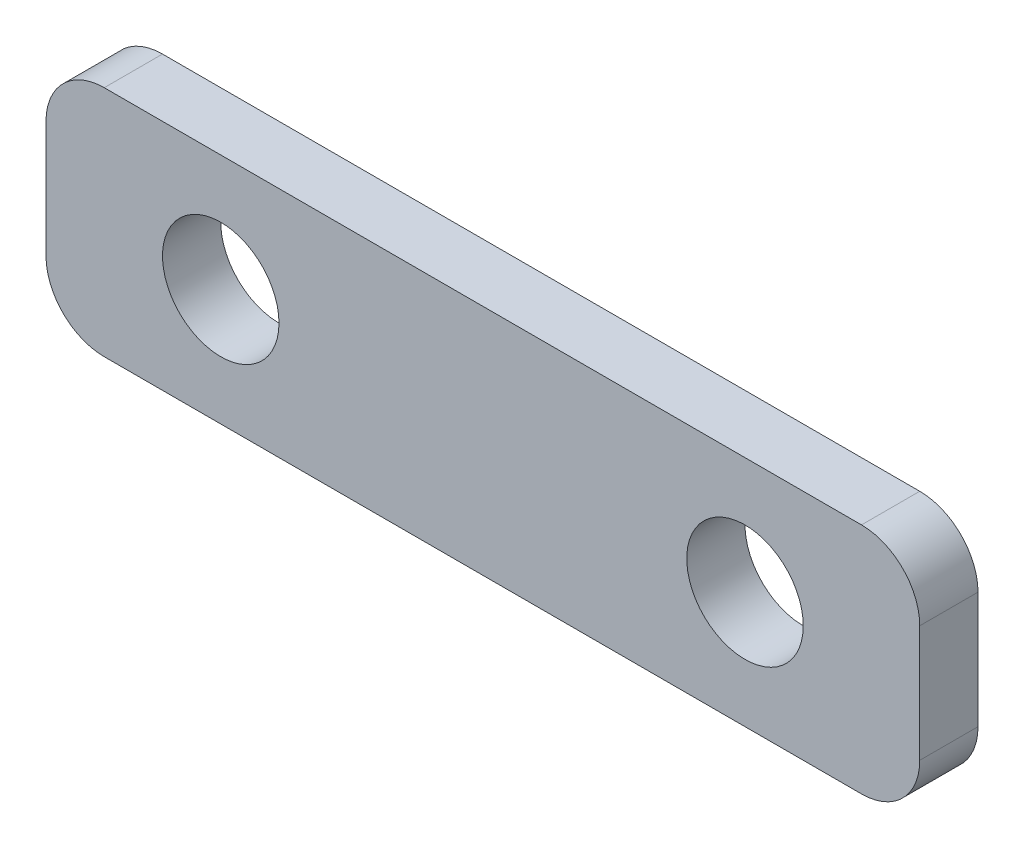
from build123d import *

# Parameters (mm, degrees)
SKETCH1_R           = 10
BOSS_EXTRUDE1_DEPTH = 5


with BuildPart() as part:
    # Sketch1 → Boss-Extrude1 (new body, symmetric)
    with BuildSketch(Plane.XY):
        with BuildLine():
            Line((-190, 151.755891263), (-60, 151.755891263))
            ThreePointArc((-60, 151.755891263), (-52.928932188, 148.826959075), (-50, 141.755891263))
            Line((-50, 141.755891263), (-50, 121.755891263))
            ThreePointArc((-50, 121.755891263), (-52.928932188, 114.684823451), (-60, 111.755891263))
            Line((-60, 111.755891263), (-190, 111.755891263))
            ThreePointArc((-190, 111.755891263), (-197.071067812, 114.684823451), (-200, 121.755891263))
            Line((-200, 121.755891263), (-200, 141.755891263))
            ThreePointArc((-200, 141.755891263), (-197.071067812, 148.826959075), (-190, 151.755891263))
        make_face()
        with Locations((-170, 131.755891263)):
            Circle(SKETCH1_R, mode=Mode.SUBTRACT)
        with Locations((-80, 131.755891263)):
            Circle(SKETCH1_R, mode=Mode.SUBTRACT)
    extrude(amount=BOSS_EXTRUDE1_DEPTH, both=True)


solid = part.part
